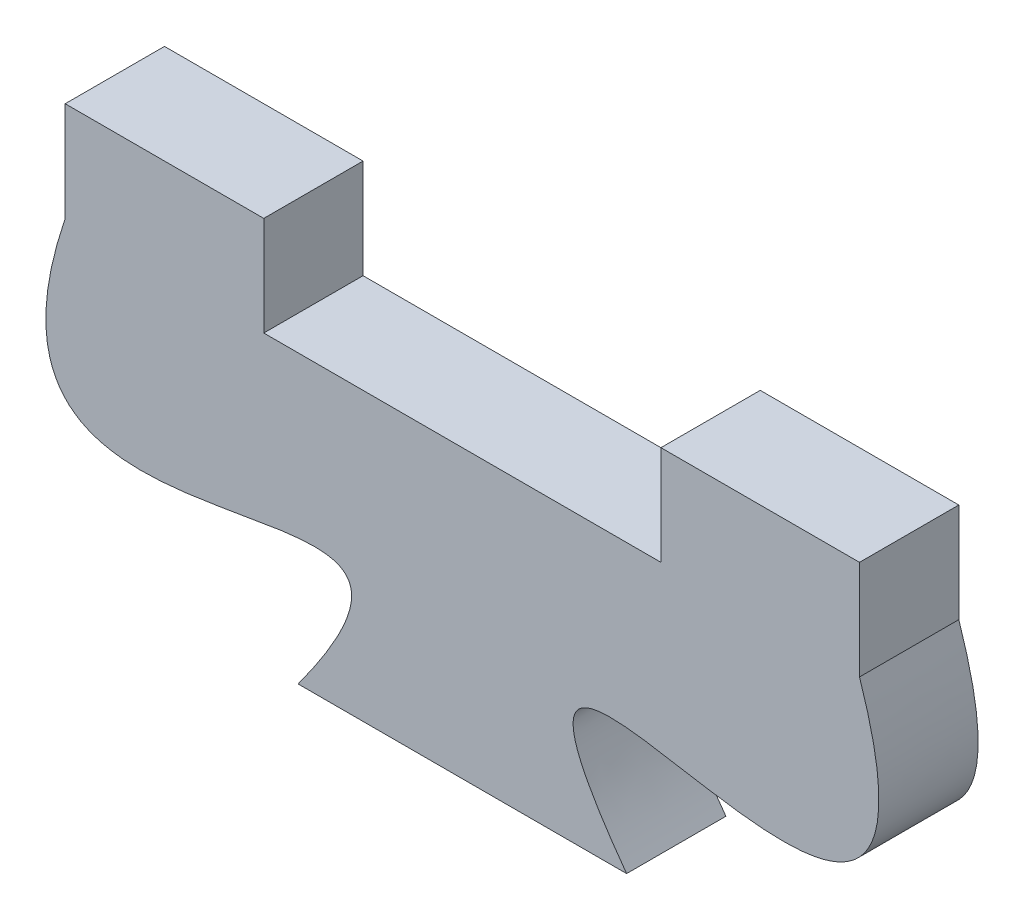
from build123d import *

# Parameters (mm, degrees)
SKETCH1_W           = 6.35
SKETCH1_H           = 3.175
BOSS_EXTRUDE1_DEPTH = 3.175


with BuildPart() as part:
    # Sketch1 → Boss-Extrude1 (new body)
    with BuildSketch(Plane.XY):
        with Locations((-63.39715008, 33.781933128)):
            Rectangle(SKETCH1_W, SKETCH1_H)
        with BuildLine():
            Line((-60.22215008, 32.194433128), (-66.57215008, 32.194433128))
            add(Edge.make_bspline(
                [(-66.57215008, 32.194433128), (-70.796112031, 19.610192525), (-51.766503484, 33.116701814), (-59.124597577, 23.025033128)],
                knots=[0, 0, 0, 0, 1, 1, 1, 1], degree=3))
            Line((-59.124597577, 23.025033128), (-48.619702582, 23.025033128))
            add(Edge.make_bspline(
                [(-41.17215008, 32.194433128), (-36.948188128, 19.610192525), (-55.977796675, 33.116701814), (-48.619702582, 23.025033128)],
                knots=[0, 0, 0, 0, 1, 1, 1, 1], degree=3))
            Line((-41.17215008, 32.194433128), (-47.52215008, 32.194433128))
            Line((-47.52215008, 32.194433128), (-60.22215008, 32.194433128))
        make_face()
        with Locations((-44.34715008, 33.781933128)):
            Rectangle(SKETCH1_W, SKETCH1_H)
    extrude(amount=BOSS_EXTRUDE1_DEPTH)


solid = part.part
